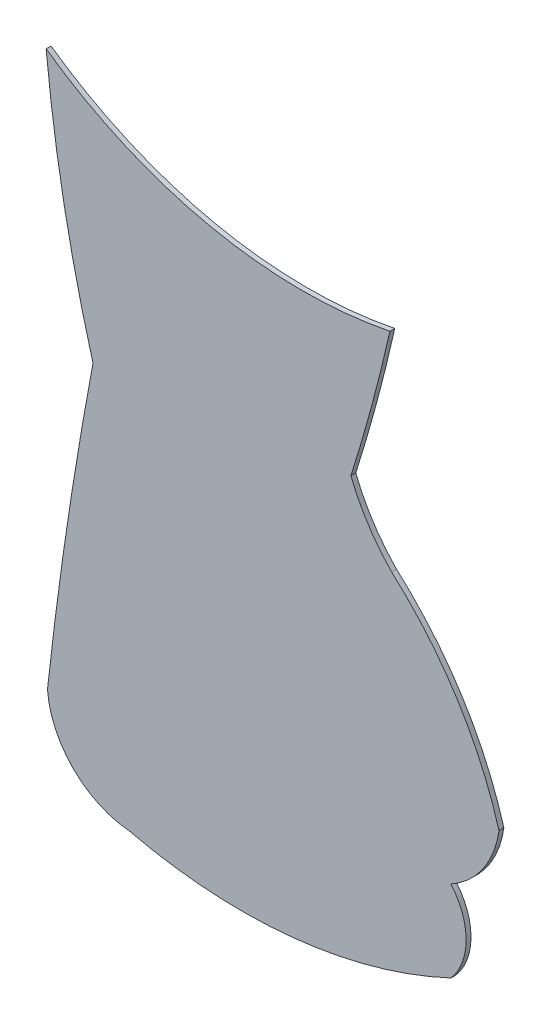
from build123d import *

# Parameters (mm, degrees)
SALIENTE_EXTRUIR1_DEPTH = 0.1


with BuildPart() as part:
    # Model → Saliente-Extruir1 (new body)
    with BuildSketch(Plane.XY):
        with BuildLine():
            ThreePointArc((5.820261238, 10.005409211), (9.186847838, 8.537831037), (12.859343802, 8.516280459))
            ThreePointArc((12.859343802, 8.516280459), (12.492089591, 7.026118334), (12.060688518, 5.553246333))
            ThreePointArc((12.060688518, 5.553246333), (12.413842974, 4.867805835), (12.894565351, 4.264935416))
            ThreePointArc((12.894565351, 4.264935416), (14.239685442, 2.677003657), (15.09298084, 0.778909273))
            ThreePointArc((15.09298084, 0.778909273), (14.77043638, -0.057438485), (14.107917756, -0.661244393))
            ThreePointArc((14.107917756, -0.661244393), (14.420283265, -1.49489014), (14.108158471, -2.328626043))
            ThreePointArc((14.108158471, -2.328626043), (10.869217247, -3.228854701), (7.514520421, -3.011688639))
            ThreePointArc((7.514520421, -3.011688639), (6.375365831, -2.483549755), (5.846898055, -1.344547705))
            ThreePointArc((5.846898055, -1.344547705), (6.252533801, 1.79168345), (6.779728877, 4.909784085))
            ThreePointArc((6.779728877, 4.909784085), (6.186082282, 7.436147735), (5.820261238, 10.005409211))
        make_face()
    extrude(amount=SALIENTE_EXTRUIR1_DEPTH)


solid = part.part
